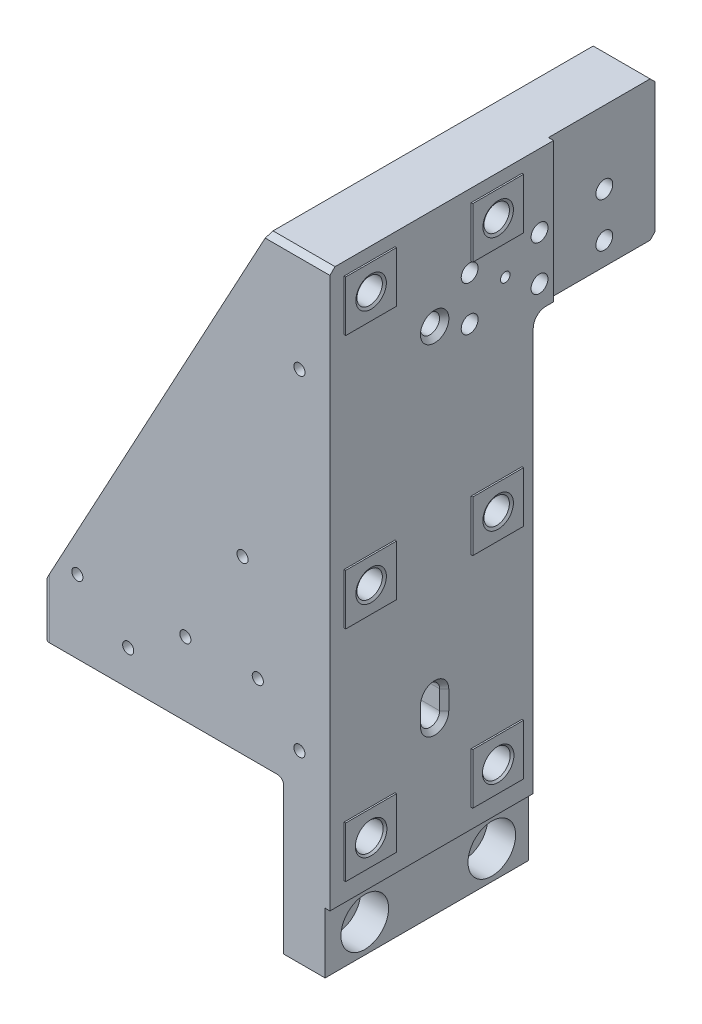
from build123d import *

# Parameters (mm, degrees)
SKETCH1_W                                     = 25.4
SKETCH1_H                                     = 309.372
EXTRUDE1_DEPTH                                = 101.6
EXTRUDE2_DEPTH                                = 53.975
EXTRUDE3_DEPTH                                = 47.625
SKETCH3_W                                     = 3.175
SKETCH3_H                                     = 31.75
CUT_EXTRUDE1_DEPTH                            = 102.6
LATERAL_HOLES_CBORE_FOR_1_2_SOCKET_H_2_COUNT  = 2
LATERAL_HOLES_CBORE_FOR_1_2_SOCKET_H_2_PITCH  = 63.5
LATERAL_HOLES_1_2_CLEARANCE_HOLE1_AT_2_COUNT  = 2
LATERAL_HOLES_1_2_CLEARANCE_HOLE1_AT_2_PITCH  = 63.5
LATERAL_HOLES_1_2_13_TAPPED_HOLE1_AT_2_COUNT  = 2
LATERAL_HOLES_1_2_13_TAPPED_HOLE1_AT_2_PITCH  = 63.5
LATERAL_HOLES_1_2_13_TAPPED_HOLE1_AT_3_COUNT  = 2
LATERAL_HOLES_1_2_13_TAPPED_HOLE1_AT_3_PITCH  = 127
LATERAL_HOLES_1_2_13_TAPPED_HOLE1_AT_4_COUNT  = 2
LATERAL_HOLES_1_2_13_TAPPED_HOLE1_AT_4_PITCH  = 141.990316571
BRACKET_HOLES_1_2_13_TAPPED_HOLE1_AT_2_COUNT  = 2
BRACKET_HOLES_1_2_13_TAPPED_HOLE1_AT_2_PITCH  = 28.575
BRACKET_HOLES_1_2_13_TAPPED_HOLE1_AT_3_COUNT  = 2
BRACKET_HOLES_1_2_13_TAPPED_HOLE1_AT_3_PITCH  = 61.072344396
BRACKET_HOLES_1_2_13_TAPPED_HOLE1_AT_4_COUNT  = 2
BRACKET_HOLES_1_2_13_TAPPED_HOLE1_AT_4_PITCH  = 53.975
BRACKET_HOLES_1_2_13_TAPPED_HOLE1_AT_5_COUNT  = 2
BRACKET_HOLES_1_2_13_TAPPED_HOLE1_AT_5_PITCH  = 90.258699859
BRACKET_HOLES_1_2_13_TAPPED_HOLE1_AT_6_COUNT  = 2
BRACKET_HOLES_1_2_13_TAPPED_HOLE1_AT_6_PITCH  = 93.458733943
SKETCH49_OUTSIDE_W                            = 174.822
SKETCH49_OUTSIDE_H                            = 382.594
SKETCH49_OUTSIDE_W_2                          = 25.4
SKETCH49_OUTSIDE_H_2                          = 25.4
LATERAL_PADS_EXTRUDE4_DEPTH                   = 0.762
THRU_VENT_HOLES_7_32_0_21875_DIAMETER_D       = 5.55625
BLIND_VENT_HOLE_7_32_0_21875_DIAMETER_D       = 5.55625
BLIND_VENT_HOLE_7_32_0_21875_DIAMETER_DEPTH   = 19.812
BLIND_VENT_HOLE_7_32_0_21875_DIAMETER_TIP     = 1.669265907
PIN_HOLE_3_8_0_375_DIAMETER_HOLE4_D           = 9.54278
PIN_HOLE_3_8_0_375_DIAMETER_HOLE4_DEPTH       = 19.05
PIN_HOLE_3_8_0_375_DIAMETER_HOLE4_CSINK_D     = 14.224
PIN_HOLE_3_8_0_375_DIAMETER_HOLE4_CSINK_ANGLE = 90
PIN_HOLE_3_8_0_375_DIAMETER_HOLE4_TIP         = 2.866940349
PIN_SLOT_EXTRUDE5_DEPTH                       = 19.05
PIN_SLOT_CHAMFER5_SIZE                        = 2.286
SKETCH58_W                                    = 15.748
SKETCH58_H                                    = 47.625
CUT_EXTRUDE2_DEPTH                            = 76.2
EXTRUDE4_DEPTH                                = 63.5
LPATTERN1_COUNT                               = 3
LPATTERN1_PITCH                               = 34.925
LPATTERN1_COUNT_DIR2                          = 2
LPATTERN1_PITCH_DIR2                          = 22.225
CHAMFER7_SIZE                                 = 2.54
SKETCH62_W                                    = 53.34
SKETCH62_H                                    = 69.85
EXTRUDE5_DEPTH                                = 2.54
F_7_32_0_21875_DIAMETER_HOLE2_D               = 5.55625
F_7_32_0_21875_DIAMETER_HOLE2_DEPTH           = 50.8
F_7_32_0_21875_DIAMETER_HOLE2_TIP             = 1.669265907
F_1_4_0_25_DIAMETER_HOLE1_D                   = 6.36778
F_1_4_0_25_DIAMETER_HOLE1_DEPTH               = 12.7
F_1_4_0_25_DIAMETER_HOLE1_CSINK_D             = 9.652
F_1_4_0_25_DIAMETER_HOLE1_CSINK_ANGLE         = 90
F_1_4_0_25_DIAMETER_HOLE1_TIP                 = 1.913074116
EXTRUDE6_DEPTH                                = 12.7
CHAMFER8_SIZE                                 = 1.651
F_3_16_0_1875_DIAMETER_HOLE1_D                = 4.7625
FILLET2_R                                     = 1.5875
FILLET3_R                                     = 3.175
CHAMFER10_SIZE                                = 1.524
FILLET4_R                                     = 6.35
CHAMFER11_SIZE                                = 2.286


with BuildPart() as part:
    # Sketch1 → Extrude1 (new body)
    with BuildSketch(Plane.XY):
        with Locations((12.7, 154.686)):
            Rectangle(SKETCH1_W, SKETCH1_H)
    extrude(amount=EXTRUDE1_DEPTH)

    # Sketch2 → Extrude2 (add)
    with BuildSketch(Plane.XY.offset(101.6)):
        Polygon((0, 309.372), (-6.35, 309.372), (-118.745, 101.6), (-118.745, 76.2), (0, 76.2), align=None)
    extrude(amount=-EXTRUDE2_DEPTH)

    # Sketch7 → Extrude3 (add)
    with BuildSketch(Plane(origin=(0, 0, 0), x_dir=(-1, 0, 0), z_dir=(0, 0, -1))):
        Polygon((0, 76.2), (22.225, 76.2), (22.225, 280.025672316), (6.35, 309.372), (0, 309.372), align=None)
    extrude(amount=-EXTRUDE3_DEPTH)

    # Sketch3 → Cut-Extrude1 (cut, through all)
    with BuildSketch(Plane.XY.offset(101.6)):
        with Locations((23.8125, 15.875)):
            Rectangle(SKETCH3_W, SKETCH3_H)
    extrude(amount=-CUT_EXTRUDE1_DEPTH, mode=Mode.SUBTRACT)

    # Sketch39 → Lateral Holes CBORE for 1/2 Socket Head Cap Screw2 (revolve, cut)
    with BuildSketch(Plane(origin=(22.225, 15.875, 81.788), x_dir=(0, 0, -1), z_dir=(0, 1, 0))):
        Polygon((0, 0), (0, 22.225), (7.874, 22.225), (6.9469, 21.2979), (6.9469, 13.97), (11.9126, 13.97), (11.9126, 0), align=None)
    lateral_holes_cbore_for_1_2_socket_head = revolve(axis=Axis((28.575, 15.875, 81.788), (-1, 0, 0)), mode=Mode.SUBTRACT)

    # Lateral Holes CBORE for 1_2 Socket H 2: Lateral Holes CBORE for 1/2 Socket Head Cap Screw2 ×2
    with Locations(*[(0, 0, -i * LATERAL_HOLES_CBORE_FOR_1_2_SOCKET_H_2_PITCH) for i in range(1, LATERAL_HOLES_CBORE_FOR_1_2_SOCKET_H_2_COUNT)]):
        add(lateral_holes_cbore_for_1_2_socket_head, mode=Mode.SUBTRACT)

    # Sketch41 → Lateral Holes 1/2 Clearance Hole1 (revolve, cut)
    with BuildSketch(Plane(origin=(25.4, 53.975, 18.288), x_dir=(0, 0, -1), z_dir=(0, 1, 0))):
        Polygon((0, 0), (0, 25.4), (7.874, 25.4), (6.94563, 24.47163), (6.94563, 0.92837), (7.874, 0), align=None)
    lateral_holes_1_2_clearance_hole1 = revolve(axis=Axis((31.75, 53.975, 18.288), (-1, 0, 0)), mode=Mode.SUBTRACT)

    # Lateral Holes 1/2 Clearance Hole1 at 2: Lateral Holes 1/2 Clearance Hole1 ×2
    with Locations(*[(0, 0, i * LATERAL_HOLES_1_2_CLEARANCE_HOLE1_AT_2_PITCH) for i in range(1, LATERAL_HOLES_1_2_CLEARANCE_HOLE1_AT_2_COUNT)]):
        add(lateral_holes_1_2_clearance_hole1, mode=Mode.SUBTRACT)

    # Sketch47 → Lateral Holes 1/2-13 Tapped Hole1 (revolve, cut)
    with BuildSketch(Plane(origin=(25.4, 290.322, 81.788), x_dir=(0, 0, -1), z_dir=(0, 1, 0))):
        Polygon((0, 0), (0, 54.019489309), (5.35813, 50.8), (5.35813, 38.1), (6.35, 38.1), (6.35, 0.733234842), (7.62, 0), align=None)
    lateral_holes_1_2_13_tapped_hole1 = revolve(axis=Axis((31.75, 290.322, 81.788), (-1, 0, 0)), mode=Mode.SUBTRACT)

    # Lateral Holes 1/2-13 Tapped Hole1 at 2: Lateral Holes 1/2-13 Tapped Hole1 ×2
    with Locations(*[(0, 0, -i * LATERAL_HOLES_1_2_13_TAPPED_HOLE1_AT_2_PITCH) for i in range(1, LATERAL_HOLES_1_2_13_TAPPED_HOLE1_AT_2_COUNT)]):
        add(lateral_holes_1_2_13_tapped_hole1, mode=Mode.SUBTRACT)

    # Lateral Holes 1/2-13 Tapped Hole1 at 3: Lateral Holes 1/2-13 Tapped Hole1 ×2
    with Locations(*[(0, -i * LATERAL_HOLES_1_2_13_TAPPED_HOLE1_AT_3_PITCH, 0) for i in range(1, LATERAL_HOLES_1_2_13_TAPPED_HOLE1_AT_3_COUNT)]):
        add(lateral_holes_1_2_13_tapped_hole1, mode=Mode.SUBTRACT)

    # Lateral Holes 1/2-13 Tapped Hole1 at 4: Lateral Holes 1/2-13 Tapped Hole1 ×2
    with Locations(*[Vector(0, -0.894427191, -0.447213595) * (i * LATERAL_HOLES_1_2_13_TAPPED_HOLE1_AT_4_PITCH) for i in range(1, LATERAL_HOLES_1_2_13_TAPPED_HOLE1_AT_4_COUNT)]):
        add(lateral_holes_1_2_13_tapped_hole1, mode=Mode.SUBTRACT)

    # Sketch43 → Bracket Holes 1/2-13 Tapped Hole1 (revolve, cut)
    with BuildSketch(Plane(origin=(-101.6, 76.2, 60.325), x_dir=(0, 0, -1), z_dir=(1, 0, 0))):
        Polygon((0, 0), (0, 47.669489309), (5.35813, 44.45), (5.35813, 31.75), (6.35, 31.75), (6.35, 0.733234842), (7.62, 0), align=None)
    bracket_holes_1_2_13_tapped_hole1 = revolve(axis=Axis((-101.6, 69.85, 60.325), (0, 1, 0)), mode=Mode.SUBTRACT)

    # Bracket Holes 1/2-13 Tapped Hole1 at 2: Bracket Holes 1/2-13 Tapped Hole1 ×2
    with Locations(*[(0, 0, i * BRACKET_HOLES_1_2_13_TAPPED_HOLE1_AT_2_PITCH) for i in range(1, BRACKET_HOLES_1_2_13_TAPPED_HOLE1_AT_2_COUNT)]):
        add(bracket_holes_1_2_13_tapped_hole1, mode=Mode.SUBTRACT)

    # Bracket Holes 1/2-13 Tapped Hole1 at 3: Bracket Holes 1/2-13 Tapped Hole1 ×2
    with Locations(*[Vector(0.883787916, 0, 0.46788772) * (i * BRACKET_HOLES_1_2_13_TAPPED_HOLE1_AT_3_PITCH) for i in range(1, BRACKET_HOLES_1_2_13_TAPPED_HOLE1_AT_3_COUNT)]):
        add(bracket_holes_1_2_13_tapped_hole1, mode=Mode.SUBTRACT)

    # Bracket Holes 1/2-13 Tapped Hole1 at 4: Bracket Holes 1/2-13 Tapped Hole1 ×2
    with Locations(*[(i * BRACKET_HOLES_1_2_13_TAPPED_HOLE1_AT_4_PITCH, 0, 0) for i in range(1, BRACKET_HOLES_1_2_13_TAPPED_HOLE1_AT_4_COUNT)]):
        add(bracket_holes_1_2_13_tapped_hole1, mode=Mode.SUBTRACT)

    # Bracket Holes 1/2-13 Tapped Hole1 at 5: Bracket Holes 1/2-13 Tapped Hole1 ×2
    with Locations(*[Vector(0.999017271, 0, 0.044322597) * (i * BRACKET_HOLES_1_2_13_TAPPED_HOLE1_AT_5_PITCH) for i in range(1, BRACKET_HOLES_1_2_13_TAPPED_HOLE1_AT_5_COUNT)]):
        add(bracket_holes_1_2_13_tapped_hole1, mode=Mode.SUBTRACT)

    # Bracket Holes 1/2-13 Tapped Hole1 at 6: Bracket Holes 1/2-13 Tapped Hole1 ×2
    with Locations(*[Vector(0.964810844, 0, -0.262944927) * (i * BRACKET_HOLES_1_2_13_TAPPED_HOLE1_AT_6_PITCH) for i in range(1, BRACKET_HOLES_1_2_13_TAPPED_HOLE1_AT_6_COUNT)]):
        add(bracket_holes_1_2_13_tapped_hole1, mode=Mode.SUBTRACT)

    # Sketch45 → Pin Hole 3/8 (0.375) Diameter Hole3 (revolve, cut)
    with BuildSketch(Plane(origin=(-76.2, 76.2, 73.025), x_dir=(0, 0, -1), z_dir=(1, 0, 0))):
        Polygon((0, 0), (0, 21.911598698), (4.7625, 19.05), (4.7625, 3.302), (4.7879, 3.302), (4.7879, 0.5461), (5.334, 0), align=None)
    revolve(axis=Axis((-76.2, 69.85, 73.025), (0, 1, 0)), mode=Mode.SUBTRACT)

    # Sketch49 outside → Lateral Pads Extrude4 (cut)
    with BuildSketch(Plane(origin=(25.4, 0, 0), x_dir=(0, 0, -1), z_dir=(1, 0, 0))):
        with Locations((-50.8, 154.686)):
            Rectangle(SKETCH49_OUTSIDE_W, SKETCH49_OUTSIDE_H)
        with Locations((-81.788, 290.322)):
            Rectangle(SKETCH49_OUTSIDE_W_2, SKETCH49_OUTSIDE_H_2, mode=Mode.SUBTRACT)
        with Locations((-18.288, 290.322)):
            Rectangle(SKETCH49_OUTSIDE_W_2, SKETCH49_OUTSIDE_H_2, mode=Mode.SUBTRACT)
        with Locations((-81.788, 53.975)):
            Rectangle(SKETCH49_OUTSIDE_W_2, SKETCH49_OUTSIDE_H_2, mode=Mode.SUBTRACT)
        with Locations((-18.288, 53.975)):
            Rectangle(SKETCH49_OUTSIDE_W_2, SKETCH49_OUTSIDE_H_2, mode=Mode.SUBTRACT)
        with Locations((-81.788, 163.322)):
            Rectangle(SKETCH49_OUTSIDE_W_2, SKETCH49_OUTSIDE_H_2, mode=Mode.SUBTRACT)
        with Locations((-18.288, 163.322)):
            Rectangle(SKETCH49_OUTSIDE_W_2, SKETCH49_OUTSIDE_H_2, mode=Mode.SUBTRACT)
    extrude(amount=-LATERAL_PADS_EXTRUDE4_DEPTH, mode=Mode.SUBTRACT)

    # Thru Vent Holes 7/32 (0.21875) Diameter Hole1 (through all)
    with Locations(Plane.XY.offset(101.6)):
        with Locations((-47.625, 114.3), (-101.6, 114.3), (-76.2, 95.25), (-11.43, 114.3)):
            Hole(THRU_VENT_HOLES_7_32_0_21875_DIAMETER_D / 2)

    # Blind Vent Hole 7/32 (0.21875) Diameter Hole3
    with Locations(Plane.XY.offset(101.6)):
        with Locations((-19.05, 163.322)):
            Hole(BLIND_VENT_HOLE_7_32_0_21875_DIAMETER_D / 2, depth=BLIND_VENT_HOLE_7_32_0_21875_DIAMETER_DEPTH)
            with Locations((0, 0, -(BLIND_VENT_HOLE_7_32_0_21875_DIAMETER_DEPTH + BLIND_VENT_HOLE_7_32_0_21875_DIAMETER_TIP / 2))):  # 118° drill point
                Cone(0, BLIND_VENT_HOLE_7_32_0_21875_DIAMETER_D / 2, BLIND_VENT_HOLE_7_32_0_21875_DIAMETER_TIP, mode=Mode.SUBTRACT)

    # Pin Hole 3/8 (0.375) Diameter Hole4
    with Locations(Plane(origin=(24.638, 0, 0), x_dir=(0, 0, -1), z_dir=(1, 0, 0))):
        with Locations((-49.276, 258.572)):
            CounterSinkHole(PIN_HOLE_3_8_0_375_DIAMETER_HOLE4_D / 2, PIN_HOLE_3_8_0_375_DIAMETER_HOLE4_CSINK_D / 2, depth=PIN_HOLE_3_8_0_375_DIAMETER_HOLE4_DEPTH, counter_sink_angle=PIN_HOLE_3_8_0_375_DIAMETER_HOLE4_CSINK_ANGLE)
            with Locations((0, 0, -(PIN_HOLE_3_8_0_375_DIAMETER_HOLE4_DEPTH + PIN_HOLE_3_8_0_375_DIAMETER_HOLE4_TIP / 2))):  # 118° drill point
                Cone(0, PIN_HOLE_3_8_0_375_DIAMETER_HOLE4_D / 2, PIN_HOLE_3_8_0_375_DIAMETER_HOLE4_TIP, mode=Mode.SUBTRACT)

    # Sketch57 → Pin Slot Extrude5 (cut)
    with BuildSketch(Plane(origin=(24.638, 0, 0), x_dir=(0, 0, -1), z_dir=(1, 0, 0))):
        with BuildLine():
            Line((-44.50461, 98.2345), (-44.50461, 88.7095))
            ThreePointArc((-44.50461, 88.7095), (-49.276, 83.93811), (-54.04739, 88.7095))
            Line((-54.04739, 88.7095), (-54.04739, 98.2345))
            ThreePointArc((-54.04739, 98.2345), (-49.276, 103.00589), (-44.50461, 98.2345))
        make_face()
    extrude(amount=-PIN_SLOT_EXTRUDE5_DEPTH, mode=Mode.SUBTRACT)

    # Pin Slot Chamfer5
    pin_slot_chamfer5_edges = [part.edges().sort_by_distance(p)[0] for p in [
        (24.638, 103.00589, 49.276),
        (24.638, 93.472, 54.04739),
        (24.638, 83.93811, 49.276),
        (24.638, 93.472, 44.50461),
    ]]
    chamfer(pin_slot_chamfer5_edges, length=PIN_SLOT_CHAMFER5_SIZE)

    # Sketch58 → Cut-Extrude2 (cut)
    with BuildSketch(Plane(origin=(0, 309.372, 0), x_dir=(1, 0, 0), z_dir=(0, 1, 0))):
        with Locations((-14.605, -23.8125)):
            Rectangle(SKETCH58_W, SKETCH58_H)
    extrude(amount=-CUT_EXTRUDE2_DEPTH, mode=Mode.SUBTRACT)

    # Sketch59 → Extrude4 (add)
    with BuildSketch(Plane(origin=(0, 0, 0), x_dir=(-1, 0, 0), z_dir=(0, 0, -1))):
        Polygon((6.35, 309.372), (6.731, 308.667688136), (6.731, 239.522), (-24.638, 239.522), (-24.638, 309.372), align=None)
    extrude(amount=EXTRUDE4_DEPTH)

    # Sketch60 → Tapped Hole for 5/16-18 Helicoil1 (revolve, cut)
    with BuildSketch(Plane(origin=(-6.731, 273.1008, -38.0746), x_dir=(0, 0, 1), z_dir=(0, 1, 0))):
        Polygon((0, 0), (0, 32.131), (4.2164, 32.131), (4.2164, 19.26336), (4.93268, 19.26336), (4.93268, 0.635), (5.56768, 0), align=None)
    tapped_hole_for_5_16_18_helicoil1 = revolve(axis=Axis((-13.081, 273.1008, -38.0746), (1, 0, 0)), mode=Mode.SUBTRACT)

    # LPattern1: Tapped Hole for 5_16-18 Helicoil1 3 × 2
    with Locations(*[(0, -j * LPATTERN1_PITCH_DIR2, i * LPATTERN1_PITCH) for i in range(LPATTERN1_COUNT) for j in range(LPATTERN1_COUNT_DIR2) if (i, j) != (0, 0)]):
        add(tapped_hole_for_5_16_18_helicoil1, mode=Mode.SUBTRACT)

    # Chamfer7
    chamfer7_edges = [part.edges().sort_by_distance(p)[0] for p in [
        (8.9535, 239.522, -63.5),
        (9.144, 309.372, -63.5),
        (9.144, 309.372, 101.6),
        (-14.478, 233.172, 0),
    ]]
    chamfer(chamfer7_edges, length=CHAMFER7_SIZE)

    # Sketch62 → Extrude5 (cut)
    with BuildSketch(Plane(origin=(24.638, 0, 0), x_dir=(0, 0, -1), z_dir=(1, 0, 0))):
        with Locations((36.83, 274.447)):
            Rectangle(SKETCH62_W, SKETCH62_H)
    extrude(amount=-EXTRUDE5_DEPTH, mode=Mode.SUBTRACT)

    # 7/32 (0.21875) Diameter Hole2
    with Locations(Plane.XY.offset(101.6)):
        with Locations((9.398, 258.572), (9.398, 93.472)):
            Hole(F_7_32_0_21875_DIAMETER_HOLE2_D / 2, depth=F_7_32_0_21875_DIAMETER_HOLE2_DEPTH)
            with Locations((0, 0, -(F_7_32_0_21875_DIAMETER_HOLE2_DEPTH + F_7_32_0_21875_DIAMETER_HOLE2_TIP / 2))):  # 118° drill point
                Cone(0, F_7_32_0_21875_DIAMETER_HOLE2_D / 2, F_7_32_0_21875_DIAMETER_HOLE2_TIP, mode=Mode.SUBTRACT)

    # 1/4 (0.25) Diameter Hole1
    with Locations(Plane.ZY.offset(6.731)):
        with Locations((13.97, 262.255)):
            CounterSinkHole(F_1_4_0_25_DIAMETER_HOLE1_D / 2, F_1_4_0_25_DIAMETER_HOLE1_CSINK_D / 2, depth=F_1_4_0_25_DIAMETER_HOLE1_DEPTH, counter_sink_angle=F_1_4_0_25_DIAMETER_HOLE1_CSINK_ANGLE)
            with Locations((0, 0, -(F_1_4_0_25_DIAMETER_HOLE1_DEPTH + F_1_4_0_25_DIAMETER_HOLE1_TIP / 2))):  # 118° drill point
                Cone(0, F_1_4_0_25_DIAMETER_HOLE1_D / 2, F_1_4_0_25_DIAMETER_HOLE1_TIP, mode=Mode.SUBTRACT)

    # Sketch70 → Extrude6 (cut)
    with BuildSketch(Plane.ZY.offset(6.731)):
        with BuildLine():
            Line((-66.675, 265.43889), (-53.975, 265.43889))
            ThreePointArc((-53.975, 265.43889), (-50.79111, 262.255), (-53.975, 259.07111))
            Line((-53.975, 259.07111), (-66.675, 259.07111))
            ThreePointArc((-66.675, 259.07111), (-69.85889, 262.255), (-66.675, 265.43889))
        make_face()
    extrude(amount=-EXTRUDE6_DEPTH, mode=Mode.SUBTRACT)

    # Chamfer8
    chamfer8_edges = [part.edges().sort_by_distance(p)[0] for p in [
        (-6.731, 259.07111, -58.7375),
        (-6.731, 262.255, -50.79111),
        (-6.731, 265.43889, -58.7375),
    ]]
    chamfer(chamfer8_edges, length=CHAMFER8_SIZE)

    # 3/16 (0.1875) Diameter Hole1 (through all)
    with Locations(Plane.ZY.offset(6.731)):
        with Locations((13.97, 262.255)):
            Hole(F_3_16_0_1875_DIAMETER_HOLE1_D / 2)

    # Fillet2
    fillet2_edges = [part.edges().sort_by_distance(p)[0] for p in [
        (0, 76.2, 50.8),
    ]]
    fillet(fillet2_edges, radius=FILLET2_R)

    # Fillet3
    fillet3_edges = [part.edges().sort_by_distance(p)[0] for p in [
        (-118.745, 88.9, 47.625),
        (-118.745, 88.9, 101.6),
    ]]
    fillet(fillet3_edges, radius=FILLET3_R)

    # Chamfer10
    chamfer10_edges = [part.edges().sort_by_distance(p)[0] for p in [
        (22.225, 0, 50.8),
        (11.1125, 0, 0),
        (-11.90625, 76.2, 0),
        (0, 37.30625, 0),
        (0, 37.30625, 101.6),
        (-0.464967985, 75.735032015, 101.6),
        (-0.464967985, 75.735032015, 0),
        (-118.745, 76.2, 74.6125),
        (-58.57875, 76.2, 101.6),
        (-68.8975, 76.2, 47.625),
        (-117.81506403, 76.2, 100.67006403),
        (-117.81506403, 76.2, 48.55493597),
        (11.1125, 0, 101.6),
    ]]
    chamfer(chamfer10_edges, length=CHAMFER10_SIZE)

    # Fillet4
    fillet4_edges = [part.edges().sort_by_distance(p)[0] for p in [
        (8.9535, 239.522, 0),
        (-14.478, 233.172, 47.625),
    ]]
    fillet(fillet4_edges, radius=FILLET4_R)

    # Chamfer11
    chamfer11_edges = [part.edges().sort_by_distance(p)[0] for p in [
        (0, 0, 50.8),
    ]]
    chamfer(chamfer11_edges, length=CHAMFER11_SIZE)


solid = part.part
